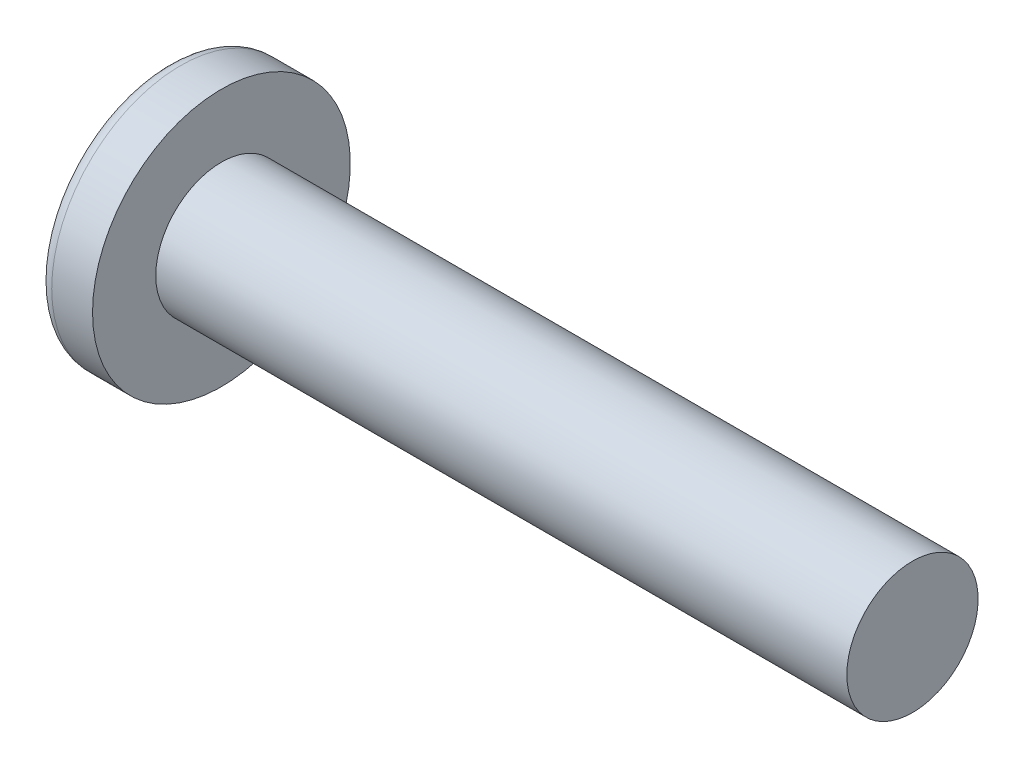
from build123d import *

# Parameters (mm, degrees)
SKETCH3_W         = 1.1684
SKETCH3_H         = 6.096
SKETCH4_W         = 0.5842
SKETCH4_H         = 0.5842
CIRPATTERN1_COUNT = 2
CIRPATTERN1_ANGLE = 90


with BuildPart() as part:
    # BodySke → Base-Revolve (revolve)
    with BuildSketch(Plane.XY):
        with BuildLine():
            Line((3.3782, 2.413), (3.3782, 4.7371))
            Line((3.3782, 4.7371), (1.87773671, 4.7371))
            ThreePointArc((1.87773671, 4.7371), (1.646685378, 4.681514944), (1.466197042, 4.526923944))
            ThreePointArc((1.466197042, 4.526923944), (0.375688687, 2.379221204), (0, 0))
            Line((0, 0), (28.7782, 0))
            Line((28.7782, 0), (28.7782, 2.413))
            Line((28.7782, 2.413), (3.3782, 2.413))
        make_face()
    revolve(axis=Axis((-25.4, 0, 0), (1, 0, 0)))

    # Sketch3 → Cut-Loft1 section 0
    with BuildSketch(Plane(origin=(0, 0, 0), x_dir=(0, 0, -1), z_dir=(1, 0, 0))):
        Rectangle(SKETCH3_W, SKETCH3_H)
    # Sketch4 → Cut-Loft1 section 1
    with BuildSketch(Plane(origin=(3.4798, 0, 0), x_dir=(0, 0, -1), z_dir=(1, 0, 0))):
        Rectangle(SKETCH4_W, SKETCH4_H)
    cut_loft1 = loft(mode=Mode.SUBTRACT)

    # CirPattern1: Cut-Loft1 ×2 about axis
    cirpattern1_axis = Axis((0, 0, 0), (1, 0, 0))
    for i in range(1, CIRPATTERN1_COUNT):
        add(cut_loft1.rotate(cirpattern1_axis, i * CIRPATTERN1_ANGLE / (CIRPATTERN1_COUNT - 1)), mode=Mode.SUBTRACT)


solid = part.part
